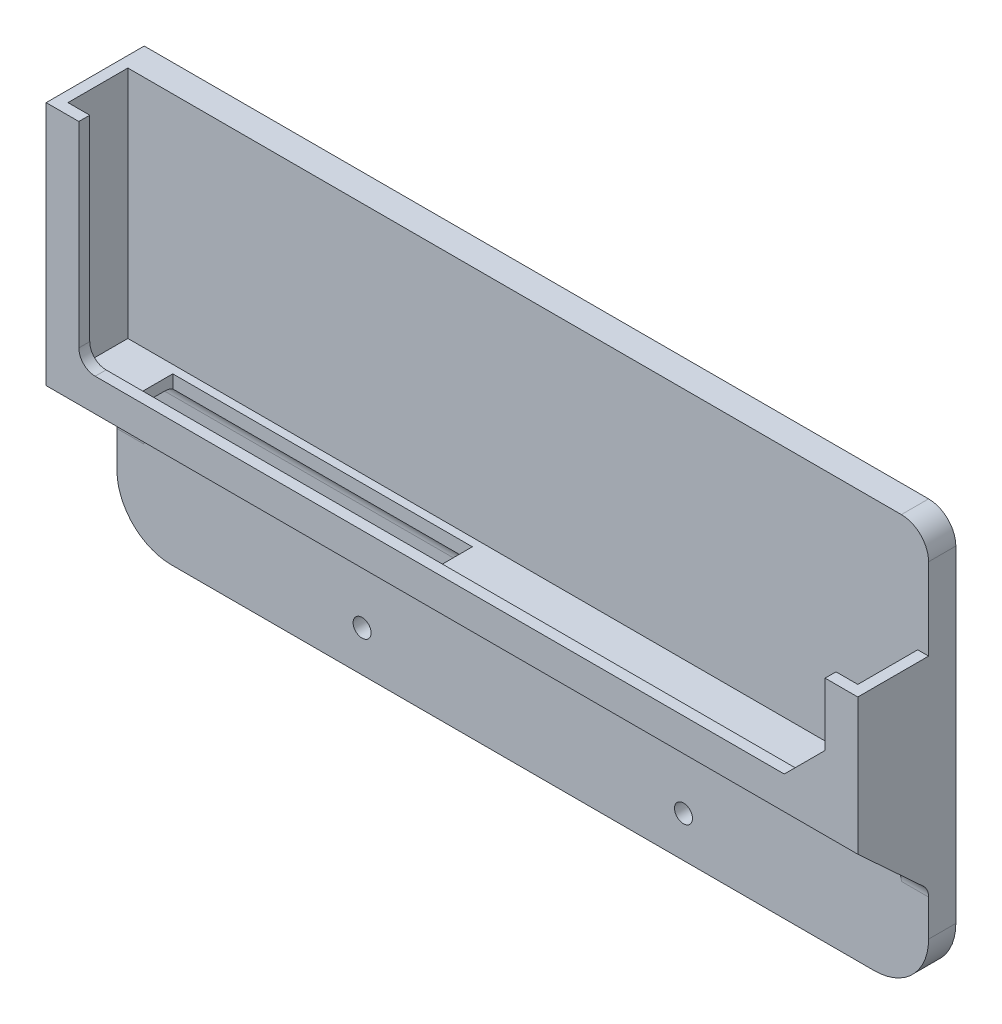
from build123d import *

# Parameters (mm, degrees)
SKETCH1_W           = 149
SKETCH1_H           = 75
SKETCH1_R           = 1.65
BOSS_EXTRUDE1_DEPTH = 5
FILLET1_R           = 10
BOSS_EXTRUDE2_DEPTH = 11
BOSS_EXTRUDE3_DEPTH = 2
CHAMFER1_SIZE       = 7.5
BOSS_EXTRUDE4_DEPTH = 5
FILLET2_R           = 3
SKETCH5_W           = 55
SKETCH5_H           = 8
CUT_EXTRUDE1_DEPTH  = 10
FILLET3_R           = 3
FILLET4_R           = 5


with BuildPart() as part:
    # Sketch1 → Boss-Extrude1 (new body)
    with BuildSketch(Plane.XY):
        with Locations((74.5, 37.5)):
            Rectangle(SKETCH1_W, SKETCH1_H)
        with Locations((45, 7.5)):
            Circle(SKETCH1_R, mode=Mode.SUBTRACT)
        with Locations((104, 7.5)):
            Circle(SKETCH1_R, mode=Mode.SUBTRACT)
    extrude(amount=BOSS_EXTRUDE1_DEPTH)

    # Fillet1
    fillet1_edges = [part.edges().sort_by_distance(p)[0] for p in [
        (149, 0, 2.5),
        (0, 0, 2.5),
    ]]
    fillet(fillet1_edges, radius=FILLET1_R)

    # Sketch2 → Boss-Extrude2 (add)
    with BuildSketch(Plane.XY.offset(5)):
        Polygon((0, 75), (2, 75), (2, 73), (2, 32), (147, 32), (147, 55), (149, 55), (149, 30), (0, 30), align=None)
    extrude(amount=BOSS_EXTRUDE2_DEPTH)

    # Sketch3 → Boss-Extrude3 (add)
    with BuildSketch(Plane.XY.offset(16)):
        Polygon((149, 30), (149, 55), (143, 55), (143, 36), (6, 36), (6, 75), (0, 75), (0, 30), align=None)
    extrude(amount=BOSS_EXTRUDE3_DEPTH)

    # Chamfer1
    chamfer1_edges = [part.edges().sort_by_distance(p)[0] for p in [
        (143, 36, 17),
    ]]
    chamfer(chamfer1_edges, length=CHAMFER1_SIZE)

    # Sketch4 → Boss-Extrude4 (add)
    with BuildSketch(Plane.ZY):
        Polygon((18, 30), (5, 18), (5, 30), align=None)
    boss_extrude4 = extrude(amount=-BOSS_EXTRUDE4_DEPTH)

    # Mirror1: Boss-Extrude4 across plane
    add(boss_extrude4.mirror(Plane.ZY.offset(-74.5)))

    # Fillet2
    fillet2_edges = [part.edges().sort_by_distance(p)[0] for p in [
        (146.5, 18, 5),
        (74.5, 30, 5),
        (2.5, 18, 5),
    ]]
    fillet(fillet2_edges, radius=FILLET2_R)

    # Sketch5 → Cut-Extrude1 (cut)
    with BuildSketch(Plane(origin=(0, 32, 0), x_dir=(1, 0, 0), z_dir=(0, 1, 0))):
        with Locations((39.241088115, -10.5)):
            Rectangle(SKETCH5_W, SKETCH5_H)
    extrude(amount=-CUT_EXTRUDE1_DEPTH, mode=Mode.SUBTRACT)

    # Fillet3
    fillet3_edges = [part.edges().sort_by_distance(p)[0] for p in [
        (6, 36, 17),
    ]]
    fillet(fillet3_edges, radius=FILLET3_R)

    # Fillet4
    fillet4_edges = [part.edges().sort_by_distance(p)[0] for p in [
        (149, 75, 2.5),
    ]]
    fillet(fillet4_edges, radius=FILLET4_R)


solid = part.part
